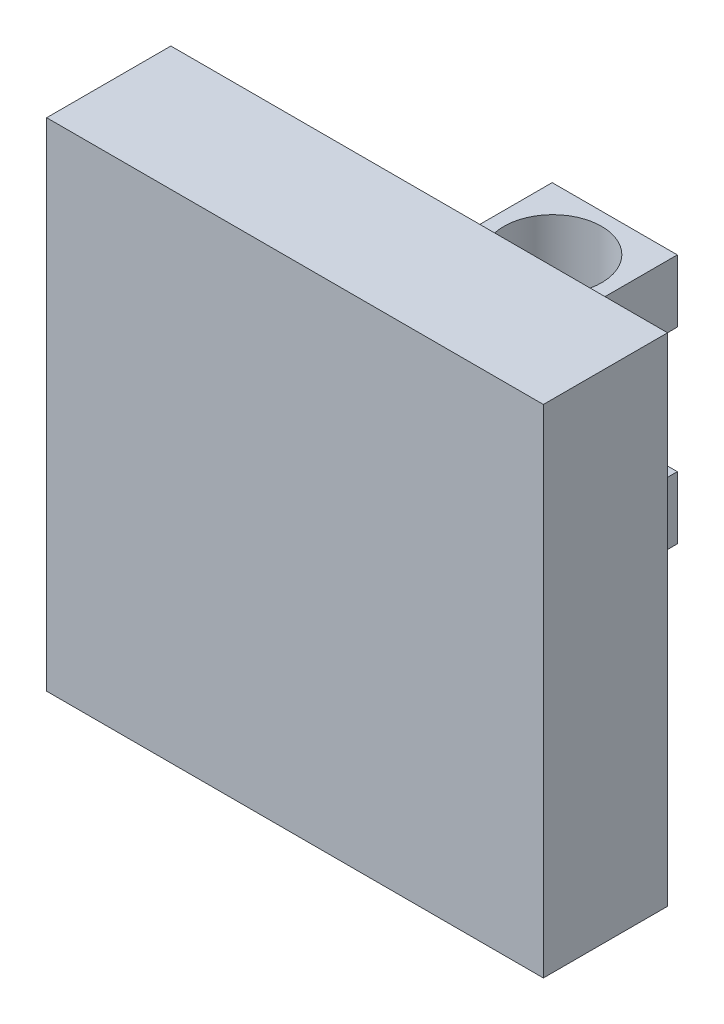
from build123d import *

# Parameters (mm, degrees)
SKETCH1_W           = 25.4
SKETCH1_H           = 25.4
BOSS_EXTRUDE1_DEPTH = 6.35
SKETCH2_W           = 6.4
SKETCH2_H           = 3.2
BOSS_EXTRUDE2_DEPTH = 10
SKETCH3_R           = 2.498733
CUT_EXTRUDE1_DEPTH  = 20.1


with BuildPart() as part:
    # Sketch1 → Boss-Extrude1 (new body)
    with BuildSketch(Plane.XY):
        Rectangle(SKETCH1_W, SKETCH1_H)
    extrude(amount=BOSS_EXTRUDE1_DEPTH)

    # Sketch2 → Boss-Extrude2 (add)
    with BuildSketch(Plane(origin=(0, 0, 0), x_dir=(-1, 0, 0), z_dir=(0, 0, -1))):
        with Locations((0, 4.8)):
            Rectangle(SKETCH2_W, SKETCH2_H)
        with Locations((0, -4.8)):
            Rectangle(SKETCH2_W, SKETCH2_H)
    extrude(amount=BOSS_EXTRUDE2_DEPTH)

    # Sketch3 → Cut-Extrude1 (cut, through all)
    with BuildSketch(Plane(origin=(0, 6.4, 0), x_dir=(1, 0, 0), z_dir=(0, 1, 0))):
        with Locations((0, 6.830385607)):
            Circle(SKETCH3_R)
    extrude(amount=-CUT_EXTRUDE1_DEPTH, mode=Mode.SUBTRACT)


solid = part.part
